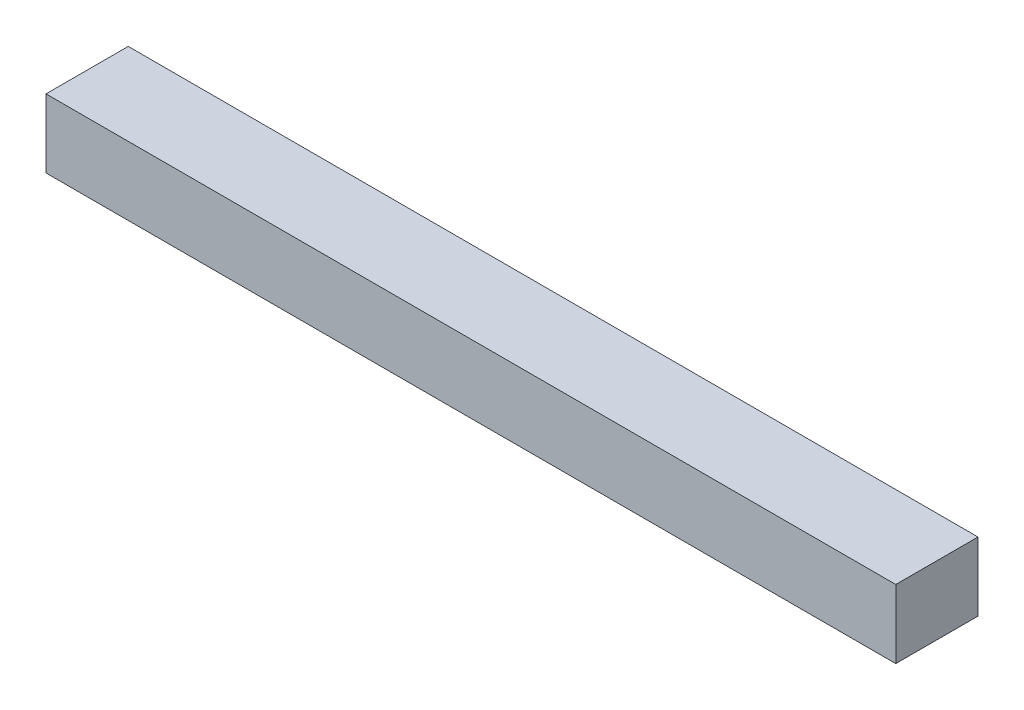
from build123d import *

# Parameters (mm, degrees)
SKETCH_2_W      = 30
SKETCH_2_H      = 25
EXTRUDE_1_DEPTH = 310


with BuildPart() as part:
    # Эскиз2 → Бобышка-Вытянуть1 (new body)
    with BuildSketch(Plane(origin=(0, 0, 0), x_dir=(0, 0, -1), z_dir=(1, 0, 0))):
        Rectangle(SKETCH_2_W, SKETCH_2_H)
    extrude(amount=EXTRUDE_1_DEPTH)


solid = part.part
